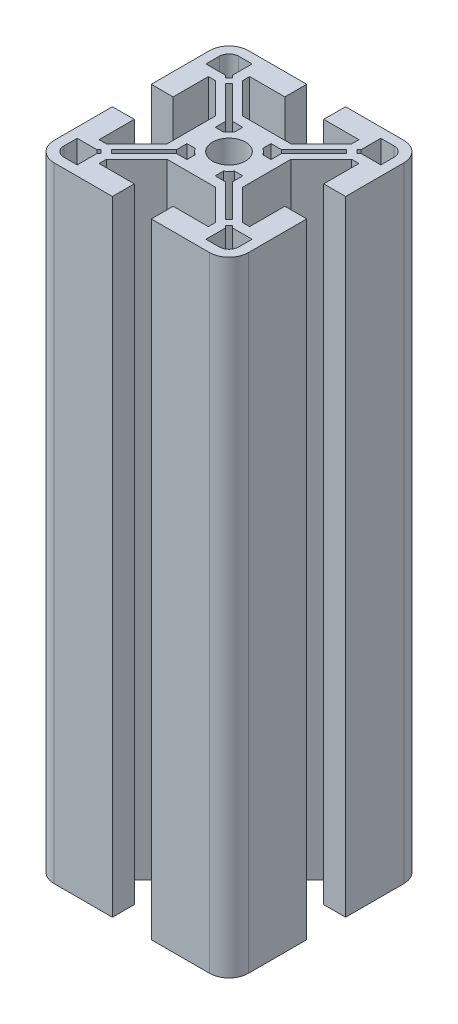
from build123d import *

# Parameters (mm, degrees)
BOSS_EXTRUDE1_DEPTH = 64.25


with BuildPart() as part:
    # Sketch1 → Boss-Extrude1 (new body, symmetric)
    with BuildSketch(Plane(origin=(0, 0, 0), x_dir=(1, 0, 0), z_dir=(0, 1, 0))):
        with BuildLine():
            Line((-27.932619, -6.859853), (-27.932619, 5.140147))
            ThreePointArc((-27.932619, 5.140147), (-26.761046, 7.968574), (-23.932619, 9.140147))
            Line((-23.932619, 9.140147), (-11.932619, 9.140147))
            Line((-11.932619, 9.140147), (-11.932619, 4.640147))
            Line((-11.932619, 4.640147), (-19.182619, 4.640147))
            Line((-19.182619, 4.640147), (-19.182619, 3.140147))
            Line((-19.182619, 3.140147), (-12.932619, -3.109853))
            Line((-12.932619, -3.109853), (-7.932619, -3.109853))
            Line((-7.932619, -3.109853), (-2.932619, -3.109853))
            Line((-2.932619, -3.109853), (3.317381, 3.140147))
            Line((3.317381, 3.140147), (3.317381, 4.640147))
            Line((3.317381, 4.640147), (-3.932619, 4.640147))
            Line((-3.932619, 4.640147), (-3.932619, 9.140147))
            Line((-3.932619, 9.140147), (8.067381, 9.140147))
            ThreePointArc((8.067381, 9.140147), (10.895808, 7.968574), (12.067381, 5.140147))
            Line((12.067381, 5.140147), (12.067381, -6.859853))
            Line((12.067381, -6.859853), (7.567381, -6.859853))
            Line((7.567381, -6.859853), (7.567381, 0.390147))
            Line((7.567381, 0.390147), (6.067381, 0.390147))
            Line((6.067381, 0.390147), (-0.182619, -5.859853))
            Line((-0.182619, -5.859853), (-0.182619, -10.859853))
            Line((-0.182619, -10.859853), (-0.182619, -15.859853))
            Line((-0.182619, -15.859853), (6.067381, -22.109853))
            Line((6.067381, -22.109853), (7.567381, -22.109853))
            Line((7.567381, -22.109853), (7.567381, -14.859853))
            Line((7.567381, -14.859853), (12.067381, -14.859853))
            Line((12.067381, -14.859853), (12.067381, -26.859853))
            ThreePointArc((12.067381, -26.859853), (10.895808, -29.68828), (8.067381, -30.859853))
            Line((8.067381, -30.859853), (-3.932619, -30.859853))
            Line((-3.932619, -30.859853), (-3.932619, -26.359853))
            Line((-3.932619, -26.359853), (3.317381, -26.359853))
            Line((3.317381, -26.359853), (3.317381, -24.859853))
            Line((3.317381, -24.859853), (-2.932619, -18.609853))
            Line((-2.932619, -18.609853), (-7.932619, -18.609853))
            Line((-7.932619, -18.609853), (-12.932619, -18.609853))
            Line((-12.932619, -18.609853), (-19.182619, -24.859853))
            Line((-19.182619, -24.859853), (-19.182619, -26.359853))
            Line((-19.182619, -26.359853), (-11.932619, -26.359853))
            Line((-11.932619, -26.359853), (-11.932619, -30.859853))
            Line((-11.932619, -30.859853), (-23.932619, -30.859853))
            ThreePointArc((-23.932619, -30.859853), (-26.761046, -29.68828), (-27.932619, -26.859853))
            Line((-27.932619, -26.859853), (-27.932619, -14.859853))
            Line((-27.932619, -14.859853), (-23.432619, -14.859853))
            Line((-23.432619, -14.859853), (-23.432619, -22.109853))
            Line((-23.432619, -22.109853), (-21.932619, -22.109853))
            Line((-21.932619, -22.109853), (-15.682619, -15.859853))
            Line((-15.682619, -15.859853), (-15.682619, -10.859853))
            Line((-15.682619, -10.859853), (-15.682619, -5.859853))
            Line((-15.682619, -5.859853), (-21.932619, 0.390147))
            Line((-21.932619, 0.390147), (-23.432619, 0.390147))
            Line((-23.432619, 0.390147), (-23.432619, -6.859853))
            Line((-23.432619, -6.859853), (-27.932619, -6.859853))
        make_face()
        with BuildLine():
            Line((-25.932619, 2.390147), (-25.932619, 5.140147))
            ThreePointArc((-25.932619, 5.140147), (-25.346832, 6.554361), (-23.932619, 7.140147))
            Line((-23.932619, 7.140147), (-21.182619, 7.140147))
            Line((-21.182619, 7.140147), (-21.182619, 3.097254))
            Line((-21.182619, 3.097254), (-20.734396, 2.649031))
            Line((-20.734396, 2.649031), (-21.441502, 1.941924))
            Line((-21.441502, 1.941924), (-21.889726, 2.390147))
            Line((-21.889726, 2.390147), (-25.932619, 2.390147))
        make_face(mode=Mode.SUBTRACT)
        with BuildLine():
            Line((-20.380842, 0.881264), (-13.682619, -5.816959))
            Line((-13.682619, -5.816959), (-13.682619, -7.955115))
            Line((-13.682619, -7.955115), (-13.182619, -7.955115))
            Line((-13.182619, -7.955115), (-12.002324, -7.955115))
            ThreePointArc((-12.002324, -7.955115), (-11.468153, -7.324319), (-10.837356, -6.790148))
            Line((-10.837356, -6.790148), (-10.837356, -5.609853))
            Line((-10.837356, -5.609853), (-10.837356, -5.109853))
            Line((-10.837356, -5.109853), (-12.975512, -5.109853))
            Line((-12.975512, -5.109853), (-19.673735, 1.588371))
            Line((-19.673735, 1.588371), (-20.380842, 0.881264))
        make_face(mode=Mode.SUBTRACT)
        with BuildLine():
            Line((10.067381, 2.390147), (10.067381, 5.140147))
            ThreePointArc((10.067381, 5.140147), (9.481595, 6.554361), (8.067381, 7.140147))
            Line((8.067381, 7.140147), (5.317381, 7.140147))
            Line((5.317381, 7.140147), (5.317381, 3.097254))
            Line((5.317381, 3.097254), (4.869158, 2.649031))
            Line((4.869158, 2.649031), (5.576265, 1.941924))
            Line((5.576265, 1.941924), (6.024488, 2.390147))
            Line((6.024488, 2.390147), (10.067381, 2.390147))
        make_face(mode=Mode.SUBTRACT)
        with BuildLine():
            Line((-2.182619, -5.816959), (-2.182619, -7.955115))
            Line((-2.182619, -7.955115), (-2.682619, -7.955115))
            Line((-2.682619, -7.955115), (-3.862914, -7.955115))
            ThreePointArc((-3.862914, -7.955115), (-4.397085, -7.324319), (-5.027881, -6.790148))
            Line((-5.027881, -6.790148), (-5.027881, -5.609853))
            Line((-5.027881, -5.609853), (-5.027881, -5.109853))
            Line((-5.027881, -5.109853), (-2.889726, -5.109853))
            Line((-2.889726, -5.109853), (3.808498, 1.588371))
            Line((3.808498, 1.588371), (4.515604, 0.881264))
            Line((4.515604, 0.881264), (-2.182619, -5.816959))
        make_face(mode=Mode.SUBTRACT)
        with BuildLine():
            Line((5.317381, -28.859853), (8.067381, -28.859853))
            ThreePointArc((8.067381, -28.859853), (9.481595, -28.274066), (10.067381, -26.859853))
            Line((10.067381, -26.859853), (10.067381, -24.109853))
            Line((10.067381, -24.109853), (6.024488, -24.109853))
            Line((6.024488, -24.109853), (5.576265, -23.661629))
            Line((5.576265, -23.661629), (4.869158, -24.368736))
            Line((4.869158, -24.368736), (5.317381, -24.816959))
            Line((5.317381, -24.816959), (5.317381, -28.859853))
        make_face(mode=Mode.SUBTRACT)
        with BuildLine():
            Line((-2.889726, -16.609853), (-5.027881, -16.609853))
            Line((-5.027881, -16.609853), (-5.027881, -16.109853))
            Line((-5.027881, -16.109853), (-5.027881, -14.929558))
            ThreePointArc((-5.027881, -14.929558), (-4.397085, -14.395387), (-3.862914, -13.76459))
            Line((-3.862914, -13.76459), (-2.682619, -13.76459))
            Line((-2.682619, -13.76459), (-2.182619, -13.76459))
            Line((-2.182619, -13.76459), (-2.182619, -15.902746))
            Line((-2.182619, -15.902746), (4.515604, -22.600969))
            Line((4.515604, -22.600969), (3.808498, -23.308076))
            Line((3.808498, -23.308076), (-2.889726, -16.609853))
        make_face(mode=Mode.SUBTRACT)
        with BuildLine():
            Line((-25.932619, -24.109853), (-25.932619, -26.859853))
            ThreePointArc((-25.932619, -26.859853), (-25.346832, -28.274066), (-23.932619, -28.859853))
            Line((-23.932619, -28.859853), (-21.182619, -28.859853))
            Line((-21.182619, -28.859853), (-21.182619, -24.816959))
            Line((-21.182619, -24.816959), (-20.734396, -24.368736))
            Line((-20.734396, -24.368736), (-21.441502, -23.661629))
            Line((-21.441502, -23.661629), (-21.889726, -24.109853))
            Line((-21.889726, -24.109853), (-25.932619, -24.109853))
        make_face(mode=Mode.SUBTRACT)
        with BuildLine():
            Line((-13.682619, -15.902746), (-13.682619, -13.76459))
            Line((-13.682619, -13.76459), (-13.182619, -13.76459))
            Line((-13.182619, -13.76459), (-12.002324, -13.76459))
            ThreePointArc((-12.002324, -13.76459), (-11.468153, -14.395387), (-10.837356, -14.929558))
            Line((-10.837356, -14.929558), (-10.837356, -16.109853))
            Line((-10.837356, -16.109853), (-10.837356, -16.609853))
            Line((-10.837356, -16.609853), (-12.975512, -16.609853))
            Line((-12.975512, -16.609853), (-19.673735, -23.308076))
            Line((-19.673735, -23.308076), (-20.380842, -22.600969))
            Line((-20.380842, -22.600969), (-13.682619, -15.902746))
        make_face(mode=Mode.SUBTRACT)
        with BuildLine():
            ThreePointArc((-11.332619, -10.859853), (-10.336782, -8.45569), (-7.932619, -7.459853))
            ThreePointArc((-7.932619, -7.459853), (-5.528456, -8.45569), (-4.532619, -10.859853))
            ThreePointArc((-4.532619, -10.859853), (-5.528456, -13.264016), (-7.932619, -14.259853))
            ThreePointArc((-7.932619, -14.259853), (-10.336782, -13.264016), (-11.332619, -10.859853))
        make_face(mode=Mode.SUBTRACT)
    extrude(amount=BOSS_EXTRUDE1_DEPTH, both=True)


solid = part.part
